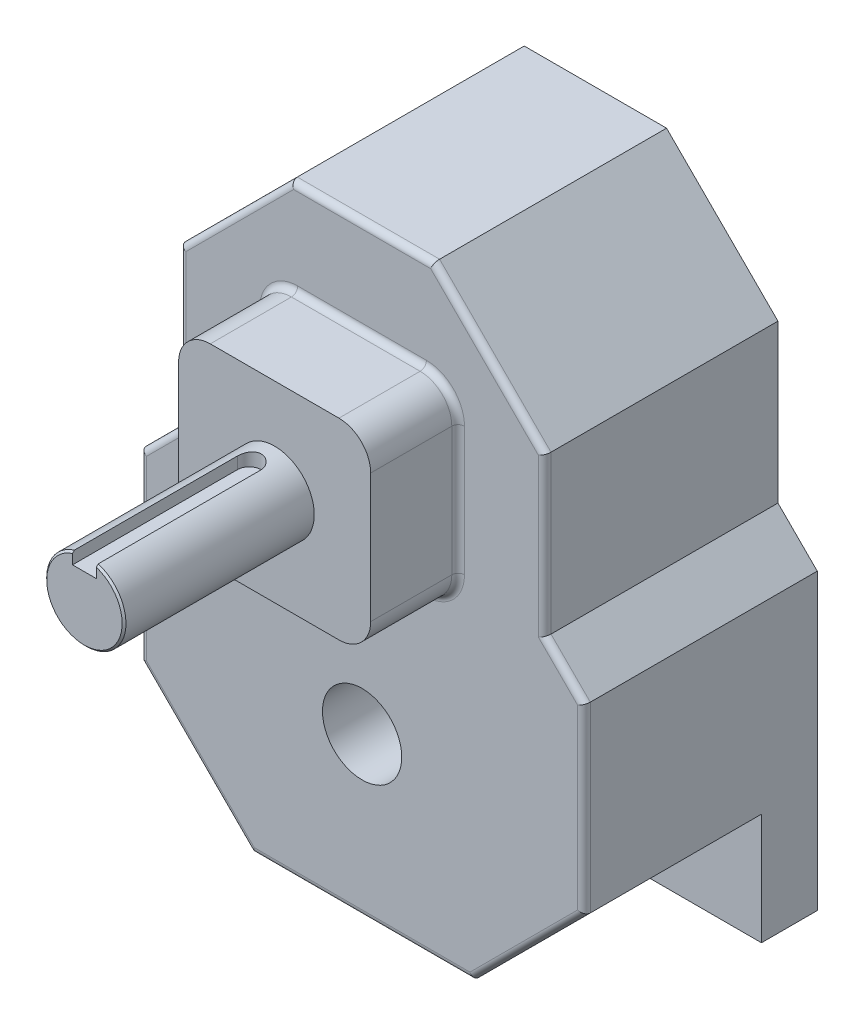
from build123d import *

# Parameters (mm, degrees)
BOSS_EXTRUDE1_DEPTH = 46.736
SKETCH3_W           = 38.481
SKETCH3_H           = 38.481
BOSS_EXTRUDE2_DEPTH = 17.526
SKETCH_D_R          = 7.9375
BOSS_EXTRUDE3_DEPTH = 38.1
CUT_EXTRUDE1_DEPTH  = 35.56
FILLET1_R           = 6.35
FILLET2_R           = 1.27
KEYWAY_START        = 5.1943
KEYWAY_DEPTH        = 33.9057
CHAMFER1_SIZE       = 0.381
SKETCH7_R           = 7.9375
CUT_EXTRUDE3_DEPTH  = 103.362


with BuildPart() as part:
    # L,M → Boss-Extrude1 (new body)
    with BuildSketch(Plane.XY):
        Polygon((-44.45, 31.75), (44.45, 31.75), (44.45, 90.644463274), (36.576, 98.518463274), (36.576, 130.081536726), (14.257536726, 152.4), (-14.257536726, 152.4), (-36.576, 130.081536726), (-36.576, 98.518463274), (-44.45, 90.644463274), align=None)
    extrude(amount=BOSS_EXTRUDE1_DEPTH)

    # Sketch3 → Boss-Extrude2 (add)
    with BuildSketch(Plane.XY.offset(46.736)):
        with Locations((0, 114.3)):
            Rectangle(SKETCH3_W, SKETCH3_H)
    extrude(amount=BOSS_EXTRUDE2_DEPTH)

    # D → Boss-Extrude3 (add)
    with BuildSketch(Plane.XY.offset(64.262)):
        with Locations((0, 114.3)):
            Circle(SKETCH_D_R)
    extrude(amount=BOSS_EXTRUDE3_DEPTH)

    # Sketch5 → Cut-Extrude1 (cut)
    with BuildSketch(Plane.XY.offset(46.736)):
        Polygon((44.45, 54.068463274), (22.131536726, 31.75), (44.45, 31.75), align=None)
        Polygon((-44.45, 31.75), (-44.45, 54.068463274), (-22.131536726, 31.75), align=None)
    extrude(amount=-CUT_EXTRUDE1_DEPTH, mode=Mode.SUBTRACT)

    # Fillet1
    fillet1_edges = [part.edges().sort_by_distance(p)[0] for p in [
        (-19.2405, 133.5405, 55.499),
        (-19.2405, 95.0595, 55.499),
        (19.2405, 95.0595, 55.499),
        (19.2405, 133.5405, 55.499),
    ]]
    fillet(fillet1_edges, radius=FILLET1_R)

    # Fillet2
    fillet2_edges = [part.edges().sort_by_distance(p)[0] for p in [
        (44.45, 72.356463274, 46.736),
        (33.290768363, 42.909231637, 46.736),
        (40.513, 94.581463274, 46.736),
        (36.576, 114.3, 46.736),
        (25.416768363, 141.240768363, 46.736),
        (0, 31.75, 46.736),
        (0, 152.4, 46.736),
        (-25.416768363, 141.240768363, 46.736),
        (-36.576, 114.3, 46.736),
        (-40.513, 94.581463274, 46.736),
        (-44.45, 72.356463274, 46.736),
        (-33.290768363, 42.909231637, 46.736),
        (0, 95.0595, 46.736),
        (-19.2405, 114.3, 46.736),
        (19.2405, 114.3, 46.736),
        (0, 133.5405, 46.736),
        (-17.380628061, 96.919371939, 46.736),
        (17.380628061, 96.919371939, 46.736),
        (-17.380628061, 131.680628061, 46.736),
        (17.380628061, 131.680628061, 46.736),
    ]]
    fillet(fillet2_edges, radius=FILLET2_R)

    # Sketch6 → Keyway (cut, through all)
    with BuildSketch(Plane(origin=(0, 114.3, 0), x_dir=(-1, 0, 0), z_dir=(0, 1, 0)).offset(KEYWAY_START)):
        with BuildLine():
            Line((2.3876, 102.362), (2.3876, 69.342))
            ThreePointArc((2.3876, 69.342), (0, 66.9544), (-2.3876, 69.342))
            Line((-2.3876, 69.342), (-2.3876, 102.362))
            ThreePointArc((-2.3876, 102.362), (0, 104.7496), (2.3876, 102.362))
        make_face()
    extrude(amount=KEYWAY_DEPTH, mode=Mode.SUBTRACT)

    # Chamfer1
    chamfer1_edges = [part.edges().sort_by_distance(p)[0] for p in [
        (-4.693204196, 107.898614164, 102.362),
    ]]
    chamfer(chamfer1_edges, length=CHAMFER1_SIZE)

    # Sketch7 → Cut-Extrude3 (cut, through all)
    with BuildSketch(Plane(origin=(0, 0, 0), x_dir=(-1, 0, 0), z_dir=(0, 0, -1))):
        with Locations((0, 63.5)):
            Circle(SKETCH7_R)
    extrude(amount=-CUT_EXTRUDE3_DEPTH, mode=Mode.SUBTRACT)


solid = part.part
